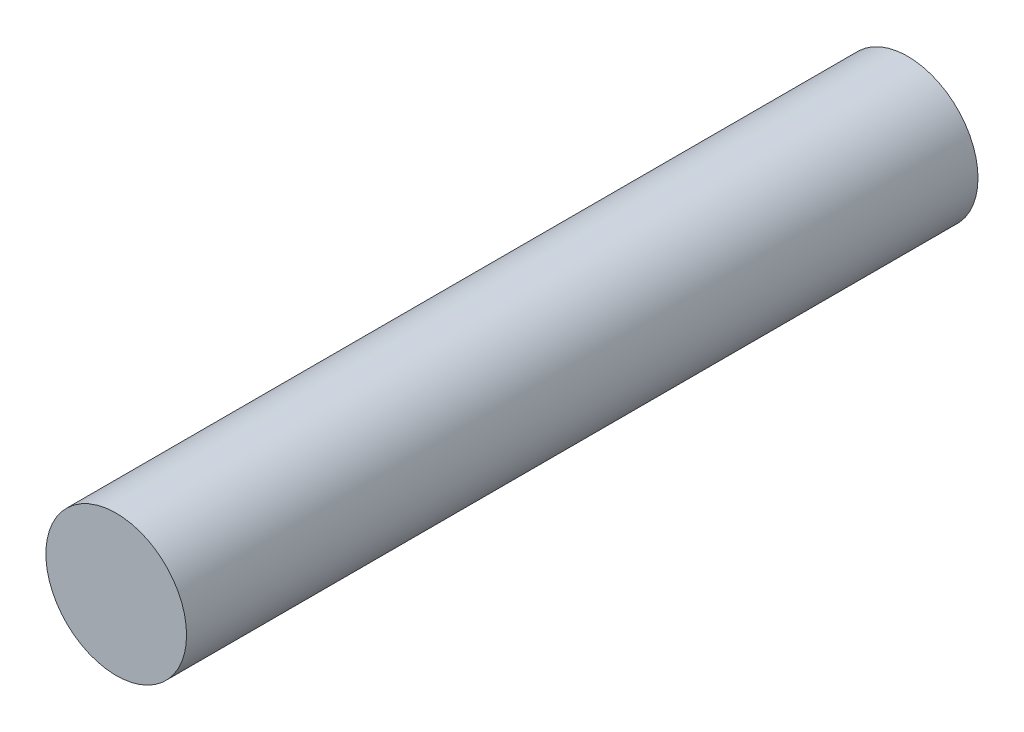
from build123d import *

# Parameters (mm, degrees)
SKETCH2_R           = 4
SKETCH2_R_2         = 2.5
BOSS_EXTRUDE1_DEPTH = 5
SKETCH3_R           = 4
BOSS_EXTRUDE2_DEPTH = 40


with BuildPart() as part:
    # Sketch2 → Boss-Extrude1 (new body)
    with BuildSketch(Plane.XY):
        Circle(SKETCH2_R)
        Circle(SKETCH2_R_2, mode=Mode.SUBTRACT)
    extrude(amount=BOSS_EXTRUDE1_DEPTH)

    # Sketch3 → Boss-Extrude2 (add)
    with BuildSketch(Plane.XY.offset(5)):
        Circle(SKETCH3_R)
    extrude(amount=BOSS_EXTRUDE2_DEPTH)


solid = part.part
